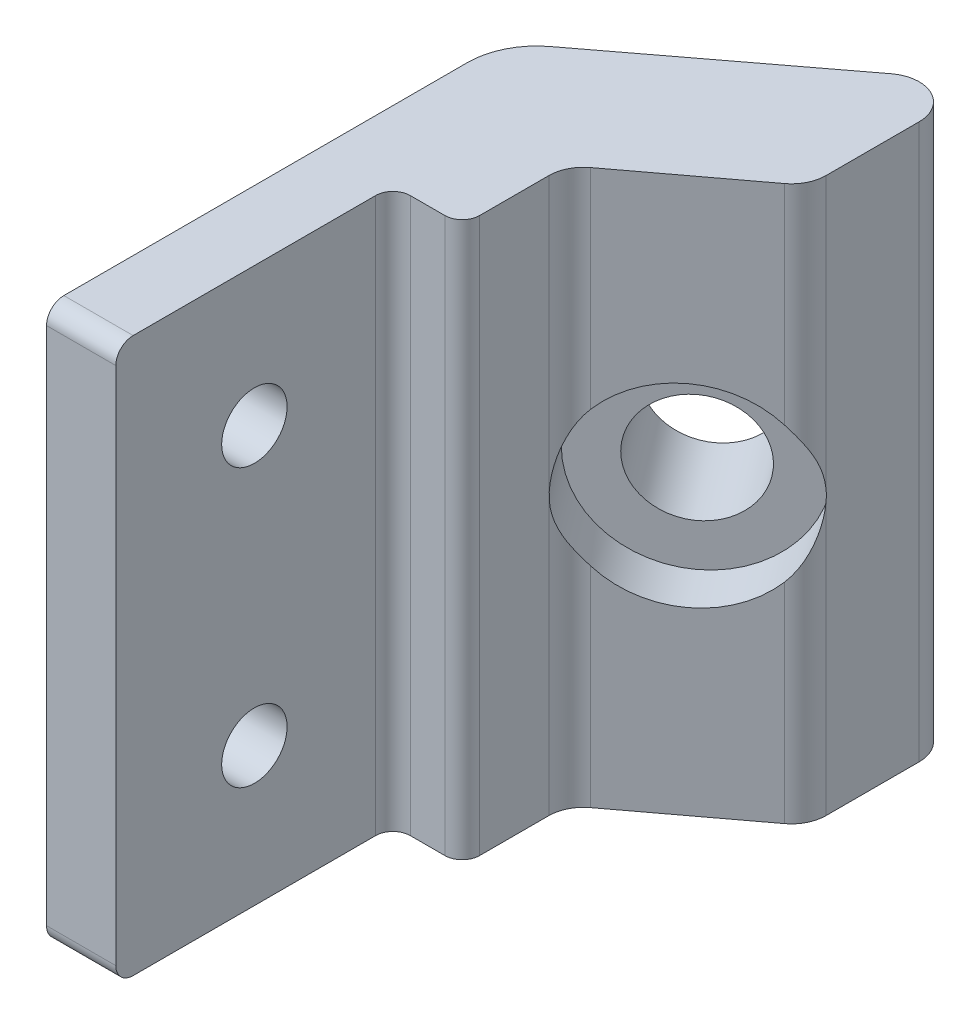
from build123d import *

# Parameters (mm, degrees)
BOSS_EXTRUDE1_DEPTH = 50.8
SKETCH15_R          = 5
CUT_EXTRUDE14_DEPTH = 8.89
SKETCH16_R          = 8.89
CUT_EXTRUDE15_DEPTH = 6.858
SKETCH17_R          = 3
CUT_EXTRUDE16_DEPTH = 6.35


with BuildPart() as part:
    # Sketch1 → Boss-Extrude1 (new body)
    with BuildSketch(Plane(origin=(0, 0, 0), x_dir=(1, 0, 0), z_dir=(0, 1, 0))):
        with BuildLine():
            Line((31.75, 0), (31.75, 13.171631631))
            Line((31.75, 13.171631631), (31.75, 38.571631565))
            ThreePointArc((31.75, 38.571631565), (32.413933313, 41.398493011), (34.266896261, 43.63422139))
            Line((34.266896261, 43.63422139), (52.058448131, 57.104967856))
            ThreePointArc((52.058448131, 57.104967856), (55.388430723, 57.416706287), (57.15, 54.573672944))
            Line((57.15, 54.573672944), (57.15, 46.0375))
            ThreePointArc((57.15, 46.0375), (56.814806331, 44.617596834), (55.88, 43.4975))
            Line((55.88, 43.4975), (45.72, 35.8775))
            ThreePointArc((45.72, 35.8775), (44.785193669, 34.757403166), (44.45, 33.3375))
            Line((44.45, 33.3375), (44.45, 26.9875))
            ThreePointArc((44.45, 26.9875), (43.985032015, 25.864967985), (42.8625, 25.4))
            Line((42.8625, 25.4), (39.6875, 25.4))
            ThreePointArc((39.6875, 25.4), (38.564967985, 24.935032015), (38.1, 23.8125))
            Line((38.1, 23.8125), (38.1, 0))
            Line((38.1, 0), (31.75, 0))
        make_face()
    extrude(amount=-BOSS_EXTRUDE1_DEPTH)

    # Sketch15 → Cut-Extrude14 (cut)
    with BuildSketch(Plane(origin=(-8.51306907, 0, -11.243676088), x_dir=(-0.79725824, 0, 0.603638384), z_dir=(-0.603638384, 0, -0.79725824))):
        with Locations((-64.492331876, -25.4)):
            Circle(SKETCH15_R)
    extrude(amount=-CUT_EXTRUDE14_DEPTH, mode=Mode.SUBTRACT)

    # Sketch16 → Cut-Extrude15 (cut)
    with BuildSketch(Plane(origin=(0.762, 0, 1.016), x_dir=(0.8, 0, -0.6), z_dir=(0.6, 0, 0.8))):
        with Locations((64.467913736, -25.4)):
            Circle(SKETCH16_R)
    extrude(amount=-CUT_EXTRUDE15_DEPTH, mode=Mode.SUBTRACT)

    # Sketch17 → Cut-Extrude16 (cut)
    with BuildSketch(Plane.ZY.offset(-31.75)):
        with Locations((-12.7, -12.7)):
            Circle(SKETCH17_R)
        with Locations((-12.7, -38.1)):
            Circle(SKETCH17_R)
        with BuildLine():
            Line((-1.5875, -50.8), (0, -50.8))
            Line((0, -50.8), (0, -49.2125))
            ThreePointArc((0, -49.2125), (-0.464967985, -50.335032015), (-1.5875, -50.8))
        make_face()
        with BuildLine():
            Line((-1.5875, 0), (0, 0))
            Line((0, 0), (0, -1.5875))
            ThreePointArc((0, -1.5875), (-0.464967985, -0.464967985), (-1.5875, 0))
        make_face()
    extrude(amount=-CUT_EXTRUDE16_DEPTH, mode=Mode.SUBTRACT)


solid = part.part
